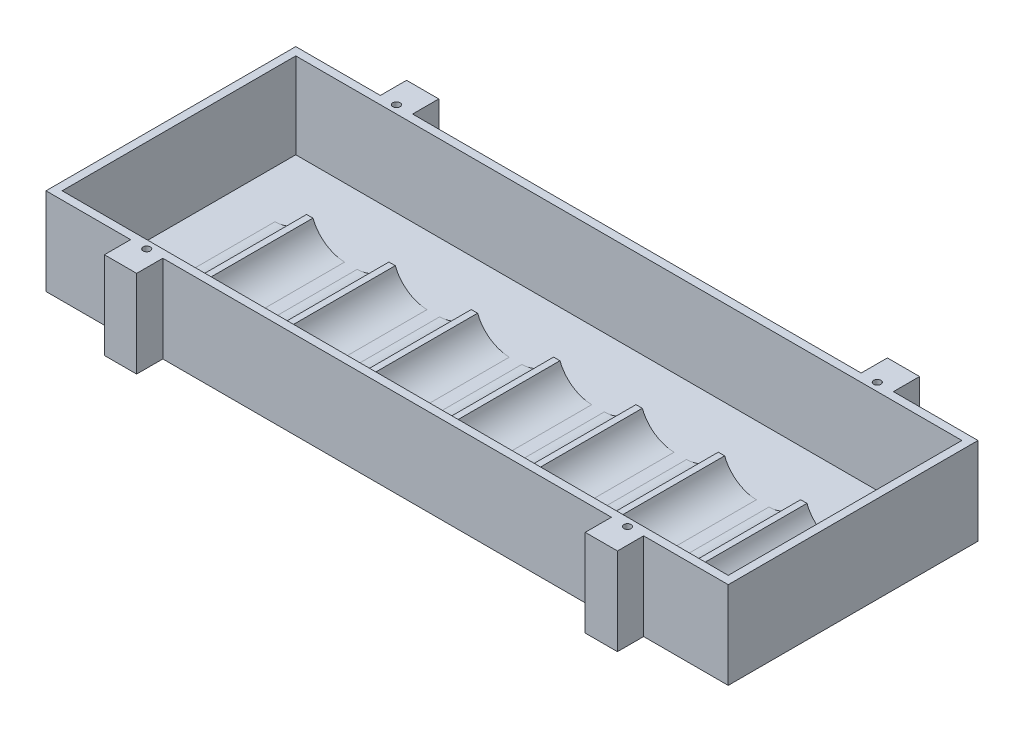
from build123d import *

# Parameters (mm, degrees)
SKETCH1_W                 = 215.08
SKETCH1_H                 = 78.74
BOSS_EXTRUDE1_DEPTH       = 0.508
SKETCH1_3_W               = 215.08
SKETCH1_3_H               = 8.255
SKETCH1_3_H_2             = 78.74
SKETCH1_3_W_2             = 210
SKETCH1_3_H_3             = 73.66
BOSS_EXTRUDE2_DEPTH       = 27
BOSS_EXTRUDE3_START       = 21.59
BOSS_EXTRUDE3_DEPTH       = 32.5
SKETCH1_4_W               = 215.08
SKETCH1_4_H               = 8.255
BOSS_EXTRUDE4_DEPTH       = 0.508
F_4_40_TAPPED_HOLE2_D     = 2.2606
F_4_40_TAPPED_HOLE2_DEPTH = 7.62
F_4_40_TAPPED_HOLE2_TIP   = 0.679152758
SKETCH13_W                = 141.42
SKETCH13_H                = 8.255
SKETCH13_W_2              = 26.67
CUT_EXTRUDE1_DEPTH        = 28.508


with BuildPart() as part:
    # Sketch1 → Boss-Extrude1 (new body)
    with BuildSketch(Plane(origin=(0, 0, 0), x_dir=(1, 0, 0), z_dir=(0, 1, 0))):
        with Locations((107.54, -39.37)):
            Rectangle(SKETCH1_W, SKETCH1_H)
    extrude(amount=-BOSS_EXTRUDE1_DEPTH)

    # Sketch1_3 → Boss-Extrude2 (add)
    with BuildSketch(Plane(origin=(0, 0, 0), x_dir=(1, 0, 0), z_dir=(0, 1, 0))):
        with Locations((107.54, 4.1275)):
            Rectangle(SKETCH1_3_W, SKETCH1_3_H)
        with Locations((107.54, -82.8675)):
            Rectangle(SKETCH1_3_W, SKETCH1_3_H)
        with Locations((107.54, -39.37)):
            Rectangle(SKETCH1_3_W, SKETCH1_3_H_2)
        with Locations((107.54, -39.37)):
            Rectangle(SKETCH1_3_W_2, SKETCH1_3_H_3, mode=Mode.SUBTRACT)
    extrude(amount=BOSS_EXTRUDE2_DEPTH)

    # Sketch5 → Boss-Extrude3 (add)
    with BuildSketch(Plane.XY.offset(2.54).offset(BOSS_EXTRUDE3_START)):
        with BuildLine():
            Line((29.54, 7), (27.54, 7))
            ThreePointArc((27.54, 7), (23.600043647, 1.985651932), (17.54, 0))
            Line((17.54, 0), (39.54, 0))
            ThreePointArc((39.54, 0), (33.479956353, 1.985651932), (29.54, 7))
        make_face()
        with BuildLine():
            Line((55.4988, 7), (53.4988, 7))
            ThreePointArc((53.4988, 7), (49.558843647, 1.985651932), (43.4988, 0))
            Line((43.4988, 0), (65.4988, 0))
            ThreePointArc((65.4988, 0), (59.438756353, 1.985651932), (55.4988, 7))
        make_face()
        with BuildLine():
            Line((81.4576, 7), (79.4576, 7))
            ThreePointArc((79.4576, 7), (75.517643647, 1.985651932), (69.4576, 0))
            Line((69.4576, 0), (91.4576, 0))
            ThreePointArc((91.4576, 0), (85.397556353, 1.985651932), (81.4576, 7))
        make_face()
        with BuildLine():
            Line((107.4164, 7), (105.4164, 7))
            ThreePointArc((105.4164, 7), (101.476443647, 1.985651932), (95.4164, 0))
            Line((95.4164, 0), (117.4164, 0))
            ThreePointArc((117.4164, 0), (111.356356353, 1.985651932), (107.4164, 7))
        make_face()
        with BuildLine():
            Line((133.3752, 7), (131.3752, 7))
            ThreePointArc((131.3752, 7), (127.435243647, 1.985651932), (121.3752, 0))
            Line((121.3752, 0), (143.3752, 0))
            ThreePointArc((143.3752, 0), (137.315156353, 1.985651932), (133.3752, 7))
        make_face()
        with BuildLine():
            Line((159.334, 7), (157.334, 7))
            ThreePointArc((157.334, 7), (153.394043647, 1.985651932), (147.334, 0))
            Line((147.334, 0), (169.334, 0))
            ThreePointArc((169.334, 0), (163.273956353, 1.985651932), (159.334, 7))
        make_face()
        with BuildLine():
            Line((185.2928, 7), (183.2928, 7))
            ThreePointArc((183.2928, 7), (179.352843647, 1.985651932), (173.2928, 0))
            Line((173.2928, 0), (195.2928, 0))
            ThreePointArc((195.2928, 0), (189.232756353, 1.985651932), (185.2928, 7))
        make_face()
    extrude(amount=BOSS_EXTRUDE3_DEPTH)

    # Sketch1_4 → Boss-Extrude4 (add)
    with BuildSketch(Plane(origin=(0, 0, 0), x_dir=(1, 0, 0), z_dir=(0, 1, 0))):
        with Locations((107.54, 4.1275)):
            Rectangle(SKETCH1_4_W, SKETCH1_4_H)
        with Locations((107.54, -82.8675)):
            Rectangle(SKETCH1_4_W, SKETCH1_4_H)
    extrude(amount=-BOSS_EXTRUDE4_DEPTH)

    # 4-40 Tapped Hole2
    with Locations(Plane(origin=(0, 27, 0), x_dir=(-1, 0, 0), z_dir=(0, 1, 0))):
        with Locations((-31.75, 0), (-183.33, 0), (-31.75, 78.74), (-183.33, 78.74)):
            Hole(F_4_40_TAPPED_HOLE2_D / 2, depth=F_4_40_TAPPED_HOLE2_DEPTH)
            with Locations((0, 0, -(F_4_40_TAPPED_HOLE2_DEPTH + F_4_40_TAPPED_HOLE2_TIP / 2))):  # 118° drill point
                Cone(0, F_4_40_TAPPED_HOLE2_D / 2, F_4_40_TAPPED_HOLE2_TIP, mode=Mode.SUBTRACT)

    # Sketch13 → Cut-Extrude1 (cut, through all)
    with BuildSketch(Plane(origin=(0, 27, 0), x_dir=(1, 0, 0), z_dir=(0, 1, 0))):
        with Locations((107.54, 4.1275)):
            Rectangle(SKETCH13_W, SKETCH13_H)
        with Locations((107.54, -82.8675)):
            Rectangle(SKETCH13_W, SKETCH13_H)
        with Locations((13.335, 4.1275)):
            Rectangle(SKETCH13_W_2, SKETCH13_H)
        with Locations((201.745, 4.1275)):
            Rectangle(SKETCH13_W_2, SKETCH13_H)
        with Locations((201.745, -82.8675)):
            Rectangle(SKETCH13_W_2, SKETCH13_H)
        with Locations((13.335, -82.8675)):
            Rectangle(SKETCH13_W_2, SKETCH13_H)
    extrude(amount=-CUT_EXTRUDE1_DEPTH, mode=Mode.SUBTRACT)


solid = part.part
